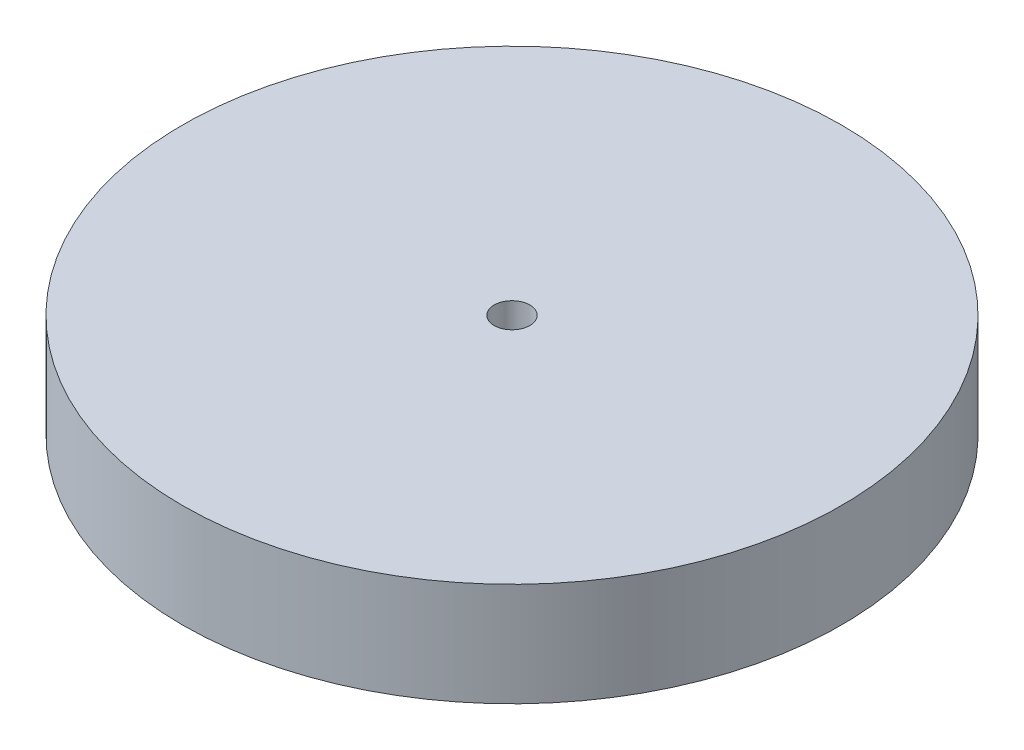
from build123d import *

# Parameters (mm, degrees)
SKETCH1_R           = 60.5
BOSS_EXTRUDE1_DEPTH = 19
SKETCH2_R           = 3.275
CUT_EXTRUDE2_DEPTH  = 20


with BuildPart() as part:
    # Sketch1 → Boss-Extrude1 (new body)
    with BuildSketch(Plane(origin=(0, 0, 0), x_dir=(1, 0, 0), z_dir=(0, 1, 0))):
        Circle(SKETCH1_R)
    extrude(amount=BOSS_EXTRUDE1_DEPTH)

    # Sketch2 → Cut-Extrude2 (cut, through all)
    with BuildSketch(Plane(origin=(0, 19, 0), x_dir=(1, 0, 0), z_dir=(0, 1, 0))):
        Circle(SKETCH2_R)
    extrude(amount=-CUT_EXTRUDE2_DEPTH, mode=Mode.SUBTRACT)


solid = part.part
